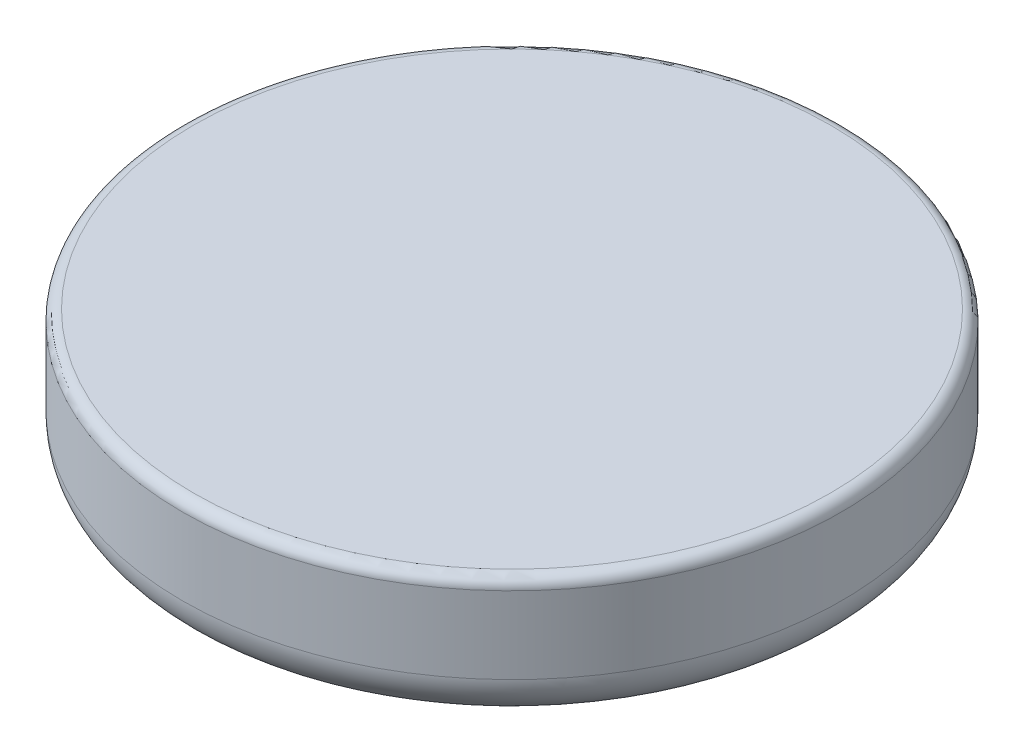
from build123d import *

# Parameters (mm, degrees)
SKETCH1_R           = 7.5
BOSS_EXTRUDE1_DEPTH = 3
FILLET1_R           = 1
CUT_EXTRUDE1_DEPTH  = 2
FILLET2_R           = 0.25


with BuildPart() as part:
    # Sketch1 → Boss-Extrude1 (new body)
    with BuildSketch(Plane(origin=(0, 0, 0), x_dir=(1, 0, 0), z_dir=(0, 1, 0))):
        with Locations(Location((0, 0, 0), (0, 0, 270))):  # turned: the seam where the file's is
            Circle(SKETCH1_R)
    extrude(amount=BOSS_EXTRUDE1_DEPTH)

    # Fillet1
    fillet1_edges = [part.edges().sort_by_distance(p)[0] for p in [
        (0, 0, -7.5),
    ]]
    fillet(fillet1_edges, radius=FILLET1_R)

    # Sketch2 → Cut-Extrude1 (cut)
    with BuildSketch(Plane.XZ):
        Polygon((-0.7, -0.7), (-0.7, -2.55), (0.7, -2.55), (0.7, -0.7), (2.55, -0.7), (2.55, 0.7), (0.7, 0.7), (0.7, 2.55), (-0.7, 2.55), (-0.7, 0.7), (-2.55, 0.7), (-2.55, -0.7), align=None)
    extrude(amount=-CUT_EXTRUDE1_DEPTH, mode=Mode.SUBTRACT)

    # Fillet2
    fillet2_edges = [part.edges().sort_by_distance(p)[0] for p in [
        (0.7, 0, -1.625),
        (1.625, 0, -0.7),
        (1.625, 0, 0.7),
        (0.7, 0, 1.625),
        (-0.7, 0, 1.625),
        (-1.625, 0, 0.7),
        (-1.625, 0, -0.7),
        (-0.7, 0, -1.625),
        (0, 3, -7.5),
    ]]
    fillet(fillet2_edges, radius=FILLET2_R)


solid = part.part
